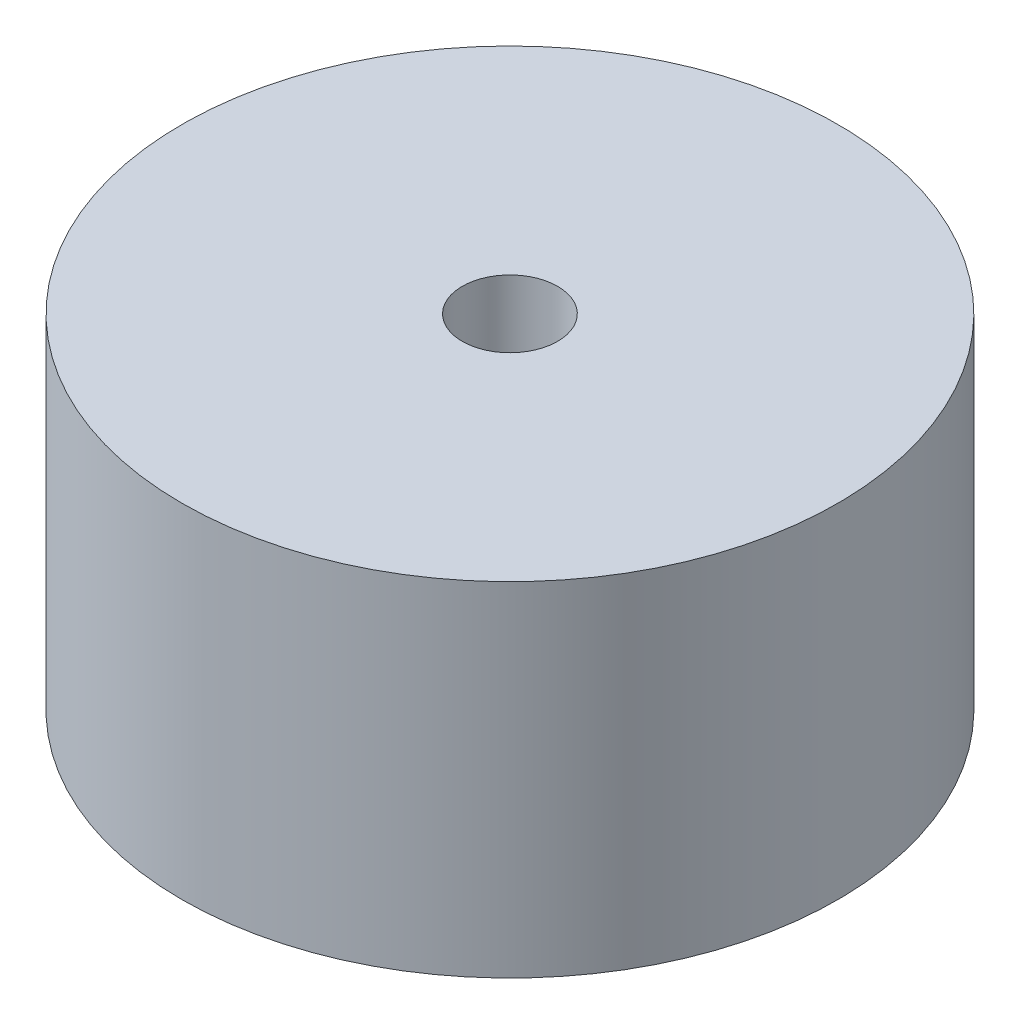
from build123d import *

# Parameters (mm, degrees)
SKETCH1_R           = 34.4
BOSS_EXTRUDE1_DEPTH = 36
SKETCH2_R           = 5.000000033
CUT_EXTRUDE1_DEPTH  = 36


with BuildPart() as part:
    # Sketch1 → Boss-Extrude1 (new body)
    with BuildSketch(Plane(origin=(0, 0, 0), x_dir=(1, 0, 0), z_dir=(0, 1, 0))):
        Circle(SKETCH1_R)
    extrude(amount=BOSS_EXTRUDE1_DEPTH)

    # Sketch2 → Cut-Extrude1 (cut)
    with BuildSketch(Plane.XZ):
        Circle(SKETCH2_R)
    extrude(amount=-CUT_EXTRUDE1_DEPTH, mode=Mode.SUBTRACT)


solid = part.part
